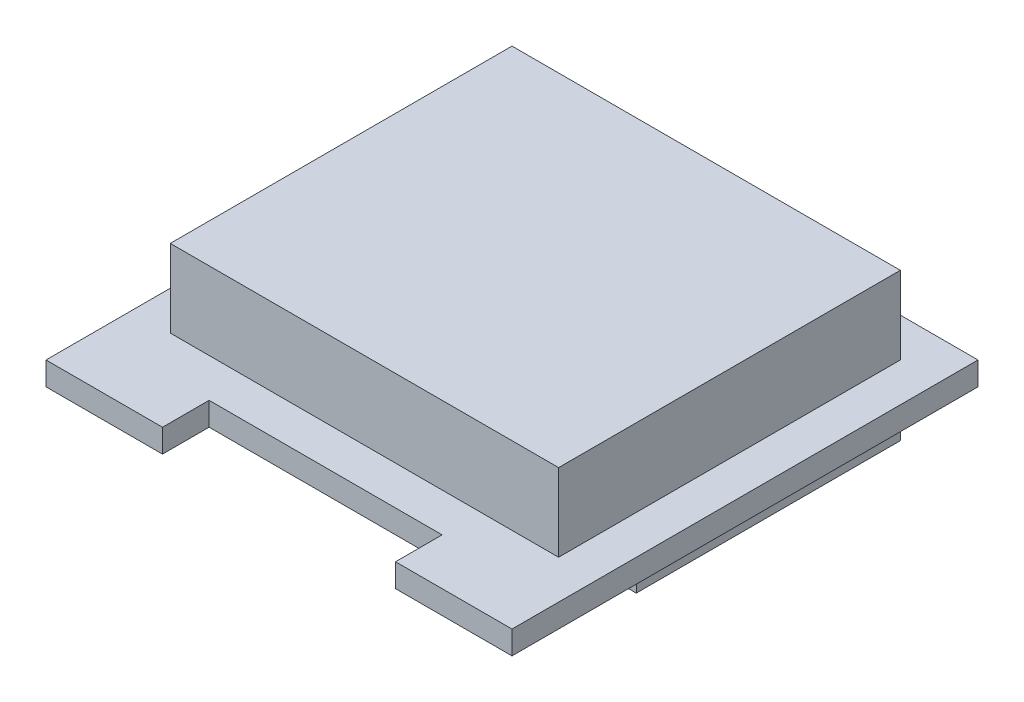
from build123d import *

# Parameters (mm, degrees)
BOSS_EXTRUDE1_DEPTH = 1.5
BOSS_EXTRUDE2_DEPTH = 5
SKETCH3_W           = 25
SKETCH3_H           = 17
BOSS_EXTRUDE3_DEPTH = 3


with BuildPart() as part:
    # Sketch1 → Boss-Extrude1 (new body)
    with BuildSketch(Plane(origin=(0, 0, 0), x_dir=(1, 0, 0), z_dir=(0, 1, 0))):
        Polygon((0, 30), (0, 0), (7.5, 0), (7.5, 3), (22.5, 3), (22.5, 0), (30, 0), (30, 30), align=None)
    extrude(amount=BOSS_EXTRUDE1_DEPTH)

    # Sketch2 → Boss-Extrude2 (add)
    with BuildSketch(Plane(origin=(0, 1.5, 0), x_dir=(1, 0, 0), z_dir=(0, 1, 0))):
        Polygon((25, 5.5), (27.5, 5.5), (27.5, 27.5), (2.5, 27.5), (2.5, 5.5), (5, 5.5), align=None)
    extrude(amount=BOSS_EXTRUDE2_DEPTH)

    # Sketch3 → Boss-Extrude3 (add)
    with BuildSketch(Plane.XZ):
        with Locations((15, -19)):
            Rectangle(SKETCH3_W, SKETCH3_H)
    extrude(amount=BOSS_EXTRUDE3_DEPTH)


solid = part.part
